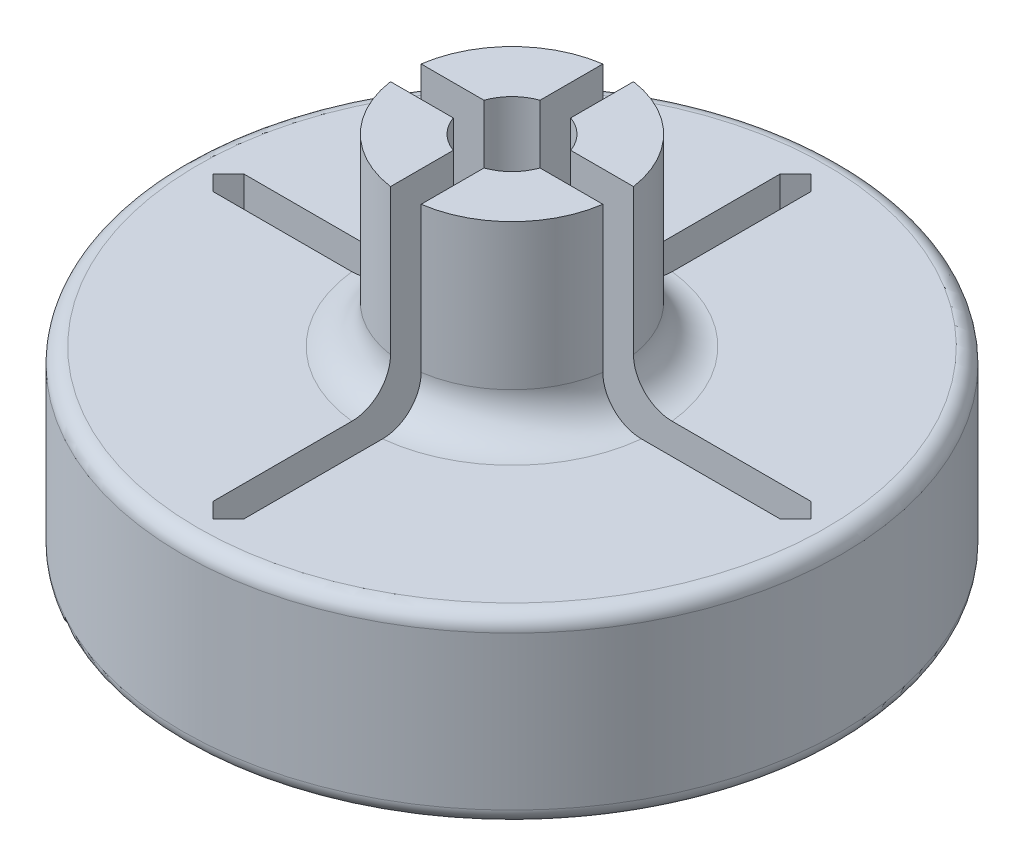
from build123d import *

# Parameters (mm, degrees)
SKETCH1_R           = 10.75
SKETCH1_R_2         = 9.75
BOSS_EXTRUDE1_DEPTH = 1
SKETCH2_R           = 10.75
SKETCH2_R_2         = 9.75
BOSS_EXTRUDE2_DEPTH = 3.5
SKETCH3_R           = 10.75
BOSS_EXTRUDE3_DEPTH = 1.5
CUT_EXTRUDE1_DEPTH  = 1
BOSS_EXTRUDE4_DEPTH = 6
FILLET1_R           = 1.25
FILLET2_R           = 0.5


with BuildPart() as part:
    # Sketch1 → Boss-Extrude1 (new body)
    with BuildSketch(Plane(origin=(0, 0, 0), x_dir=(1, 0, 0), z_dir=(0, 1, 0))):
        with Locations(Location((0, 0, 0), (0, 0, 270))):
            Circle(SKETCH1_R)
        Circle(SKETCH1_R_2, mode=Mode.SUBTRACT)
        Circle(SKETCH1_R_2)
    extrude(amount=BOSS_EXTRUDE1_DEPTH)

    # Sketch2 → Boss-Extrude2 (add)
    with BuildSketch(Plane(origin=(0, 1, 0), x_dir=(1, 0, 0), z_dir=(0, 1, 0))):
        with Locations(Location((0, 0, 0), (0, 0, 270))):
            Circle(SKETCH2_R)
        with Locations(Location((0, 0, 0), (0, 0, 270))):
            Circle(SKETCH2_R_2, mode=Mode.SUBTRACT)
    extrude(amount=BOSS_EXTRUDE2_DEPTH)

    # Sketch3 → Boss-Extrude3 (add)
    with BuildSketch(Plane(origin=(0, 4.5, 0), x_dir=(1, 0, 0), z_dir=(0, 1, 0))):
        with Locations(Location((0, 0, 0), (0, 0, 270))):
            Circle(SKETCH3_R)
    extrude(amount=BOSS_EXTRUDE3_DEPTH)

    # Sketch4 → Cut-Extrude1 (cut)
    with BuildSketch(Plane(origin=(0, 6, 0), x_dir=(1, 0, 0), z_dir=(0, 1, 0))):
        Polygon((-9.25, -0.5), (-9.75, 0), (-9.25, 0.5), (-0.5, 0.5), (-0.5, 9.25), (0, 9.75), (0.5, 9.25), (0.5, 0.5), (9.25, 0.5), (9.75, 0), (9.25, -0.5), (0.5, -0.5), (0.5, -9.25), (0, -9.75), (-0.5, -9.25), (-0.5, -0.5), align=None)
        with BuildLine():
            ThreePointArc((-1.414213562, -0.5), (-1.5, 0), (-1.414213562, 0.5))
            Line((-1.414213562, 0.5), (-9.25, 0.5))
            Line((-9.25, 0.5), (-9.75, 0))
            Line((-9.75, 0), (-9.25, -0.5))
            Line((-9.25, -0.5), (-1.414213562, -0.5))
        make_face()
        with BuildLine():
            Line((9.25, 0.5), (1.414213562, 0.5))
            ThreePointArc((1.414213562, 0.5), (1.478397839, 0.253652968), (1.5, 0))
            ThreePointArc((1.5, 0), (1.478397839, -0.253652968), (1.414213562, -0.5))
            Line((1.414213562, -0.5), (9.25, -0.5))
            Line((9.25, -0.5), (9.75, 0))
            Line((9.75, 0), (9.25, 0.5))
        make_face()
        with BuildLine():
            Line((-0.5, 9.25), (-0.5, 1.414213562))
            ThreePointArc((-0.5, 1.414213562), (0, 1.5), (0.5, 1.414213562))
            Line((0.5, 1.414213562), (0.5, 9.25))
            Line((0.5, 9.25), (0, 9.75))
            Line((0, 9.75), (-0.5, 9.25))
        make_face()
        with BuildLine():
            ThreePointArc((0.5, -1.414213562), (0, -1.5), (-0.5, -1.414213562))
            Line((-0.5, -1.414213562), (-0.5, -9.25))
            Line((-0.5, -9.25), (0, -9.75))
            Line((0, -9.75), (0.5, -9.25))
            Line((0.5, -9.25), (0.5, -1.414213562))
        make_face()
        with BuildLine():
            Line((-0.5, -0.5), (-1.414213562, -0.5))
            ThreePointArc((-1.414213562, -0.5), (-1.060660172, -1.060660172), (-0.5, -1.414213562))
            Line((-0.5, -1.414213562), (-0.5, -0.5))
        make_face()
        with BuildLine():
            Line((-1.414213562, 0.5), (-0.5, 0.5))
            Line((-0.5, 0.5), (-0.5, 1.414213562))
            ThreePointArc((-0.5, 1.414213562), (-1.060660172, 1.060660172), (-1.414213562, 0.5))
        make_face()
        with BuildLine():
            ThreePointArc((1.414213562, 0.5), (1.060660172, 1.060660172), (0.5, 1.414213562))
            Line((0.5, 1.414213562), (0.5, 0.5))
            Line((0.5, 0.5), (1.414213562, 0.5))
        make_face()
        with BuildLine():
            Line((0.5, -0.5), (0.5, -1.414213562))
            ThreePointArc((0.5, -1.414213562), (1.060660172, -1.060660172), (1.414213562, -0.5))
            Line((1.414213562, -0.5), (0.5, -0.5))
        make_face()
    extrude(amount=-CUT_EXTRUDE1_DEPTH, mode=Mode.SUBTRACT)

    # Sketch6 → Boss-Extrude4 (add)
    with BuildSketch(Plane(origin=(0, 6, 0), x_dir=(1, 0, 0), z_dir=(0, 1, 0))):
        with BuildLine():
            Line((0.5, 1.414213562), (0.5, 3.464101615))
            ThreePointArc((0.5, 3.464101615), (2.474873734, 2.474873734), (3.464101615, 0.5))
            Line((3.464101615, 0.5), (1.414213562, 0.5))
            ThreePointArc((1.414213562, 0.5), (1.060660172, 1.060660172), (0.5, 1.414213562))
        make_face()
        with BuildLine():
            Line((0.5, -1.414213562), (0.5, -3.464101615))
            ThreePointArc((0.5, -3.464101615), (2.474873734, -2.474873734), (3.464101615, -0.5))
            Line((3.464101615, -0.5), (1.414213562, -0.5))
            ThreePointArc((1.414213562, -0.5), (1.060660172, -1.060660172), (0.5, -1.414213562))
        make_face()
        with BuildLine():
            Line((-1.414213562, -0.5), (-3.464101615, -0.5))
            ThreePointArc((-3.464101615, -0.5), (-2.474873734, -2.474873734), (-0.5, -3.464101615))
            Line((-0.5, -3.464101615), (-0.5, -1.414213562))
            ThreePointArc((-0.5, -1.414213562), (-1.060660172, -1.060660172), (-1.414213562, -0.5))
        make_face()
        with BuildLine():
            Line((-0.5, 1.414213562), (-0.5, 3.464101615))
            ThreePointArc((-0.5, 3.464101615), (-2.474873734, 2.474873734), (-3.464101615, 0.5))
            Line((-3.464101615, 0.5), (-1.414213562, 0.5))
            ThreePointArc((-1.414213562, 0.5), (-1.060660172, 1.060660172), (-0.5, 1.414213562))
        make_face()
    extrude(amount=BOSS_EXTRUDE4_DEPTH)

    # Fillet1
    fillet1_edges = [part.edges().sort_by_distance(p)[0] for p in [
        (-2.474873734, 6, 2.474873734),
        (-2.474873734, 6, -2.474873734),
        (2.474873734, 6, -2.474873734),
        (2.474873734, 6, 2.474873734),
    ]]
    fillet(fillet1_edges, radius=FILLET1_R)

    # Fillet2
    fillet2_edges = [part.edges().sort_by_distance(p)[0] for p in [
        (0, 6, -10.75),
        (0, 0, -10.75),
    ]]
    fillet(fillet2_edges, radius=FILLET2_R)


solid = part.part
